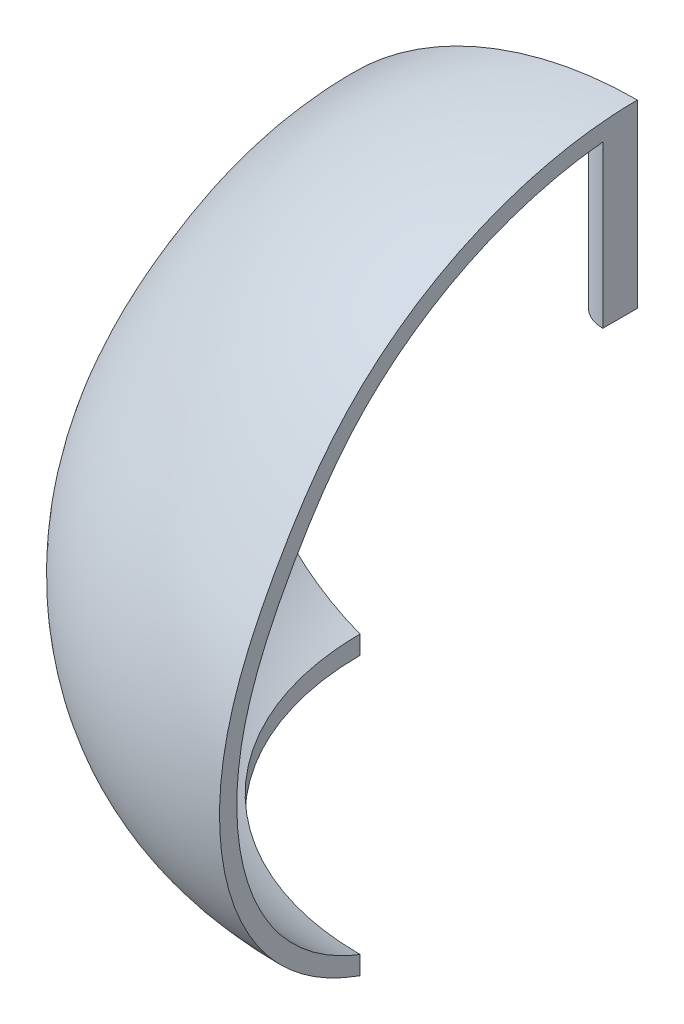
from build123d import *

# Parameters (mm, degrees)
SKETCH4_R           = 80.100145108
CUT_EXTRUDE2_DEPTH  = 20
CUT_EXTRUDE3_DEPTH  = 121.706010599
BOSS_EXTRUDE1_REACH = 54.085
SKETCH6_R           = 10
SKETCH7_W           = 348.912782296
SKETCH7_H           = 364.592796888
CUT_EXTRUDE4_DEPTH  = 159
SKETCH8_W           = 326.819124442
SKETCH8_H           = 332.894396065
CUT_EXTRUDE5_DEPTH  = 200


with BuildPart() as part:
    # Sketch3 → Revolve5 (revolve)
    with BuildSketch(Plane.XY):
        with BuildLine():
            Line((0.02453969, 157.084900749), (0.02453969, 152.084900749))
            add(Edge.make_bspline(
                [(-103.174583613, -2.6432e-05), (-114.760245555, 14.576189089), (-119.836740195, 49.27275863), (-101.45175109, 88.673946708), (-71.379831841, 134.479430747), (-29.75001244, 152.084900749), (0.02453969, 152.084900749)],
                knots=[0, 0, 0, 0, 0.250738493, 0.442513363, 0.587644713, 1, 1, 1, 1], degree=3))
            add(Edge.make_bspline(
                [(-103.174583613, -2.6432e-05), (-78.832759046, -30.064140021), (-33.458723298, -20.943389124), (0.02453969, -20.943389124)],
                knots=[0, 0, 0, 0, 1, 1, 1, 1], degree=3))
            Line((0.02453969, -20.943389124), (0.02453969, -25.943389124))
            add(Edge.make_bspline(
                [(0.02453969, -25.943389124), (-1.007843071, -25.943389124), (-3.05274325, -25.960735741), (-7.300680211, -26.054029266), (-12.774839269, -26.259816275), (-19.586870399, -26.581007249), (-28.911339242, -27.014332449), (-40.900445748, -27.386982651), (-55.443773123, -26.975342887), (-69.789912797, -25.08625158), (-81.278725906, -21.722461367), (-89.959801918, -17.60281584), (-96.13825684, -13.717797758), (-100.945853349, -9.752185194), (-104.534382709, -6.13029221), (-106.254478554, -4.141899361), (-107.07473695, -3.128814187)],
                knots=[-0.000194385, -0.000194385, -0.000194385, -0.000194385, 0.03106169, 0.062317764, 0.124829913, 0.187342062, 0.249854211, 0.37487851, 0.499902808, 0.624927106, 0.749951404, 0.812463553, 0.874975702, 0.937487851, 0.968743925, 1, 1, 1, 1], degree=3))
            add(Edge.make_bspline(
                [(-107.07473695, -3.128814187), (-107.861659129, -2.138767408), (-109.375579618, -0.100482773), (-112.095489807, 4.115600278), (-114.955951775, 9.644100323), (-117.55365357, 16.585319153), (-119.962688147, 26.134623726), (-121.103112226, 38.406473215), (-119.79356064, 53.088411426), (-116.089945574, 67.047457773), (-110.633897624, 80.23296506), (-104.034329909, 92.718986198), (-96.815301706, 104.751602155), (-88.512248671, 116.246845317), (-78.667704424, 126.697829164), (-67.464684594, 135.71357688), (-55.182594106, 143.280590712), (-42.054195525, 149.310974483), (-28.321126938, 153.731407172), (-14.204212291, 156.457352496), (-4.722534611, 157.084900749), (0.02453969, 157.084900749)],
                knots=[-0.000101258, -0.000101258, -0.000101258, -0.000101258, 0.015525324, 0.031151906, 0.06240507, 0.093658235, 0.124911399, 0.187417728, 0.249924056, 0.312430385, 0.374936714, 0.437443042, 0.499949371, 0.562455699, 0.624962028, 0.687468357, 0.749974685, 0.812481014, 0.874987343, 0.937493671, 1, 1, 1, 1], degree=3))
        make_face()
    revolve(axis=Axis((0.02453969, 171.610282588, 0), (0, -1, 0)))

    # Sketch4 → Cut-Extrude2 (cut)
    with BuildSketch(Plane(origin=(0, -30, 0), x_dir=(1, 0, 0), z_dir=(0, 1, 0))):
        Circle(SKETCH4_R)
    extrude(amount=CUT_EXTRUDE2_DEPTH, mode=Mode.SUBTRACT)

    # Sketch5 → Cut-Extrude3 (cut, through all)
    with BuildSketch(Plane(origin=(0, 0, 0), x_dir=(0, 0, -1), z_dir=(1, 0, 0))):
        with BuildLine():
            Line((-52.476481645, 8.136577936), (52.476481645, 8.136577936))
            ThreePointArc((52.476481645, 8.136577936), (58.138069368, 8.954648303), (63.336499377, 11.341935492))
            add(Edge.make_bspline(
                [(63.336499377, 11.341935492), (82.622361185, 23.812864951), (78.746201445, 39.317958114)],
                knots=[5.637022825, 5.637022825, 5.637022825, 6.404500867, 6.404500867, 6.404500867], degree=2, weights=[1, 0.927271268, 1]))
            ThreePointArc((78.746201445, 39.317958114), (77.929706658, 42.769255575), (77.20089719, 46.240127895))
            add(Edge.make_bspline(
                [(70.494135614, 63.047069033), (72.356334923, 60.10156835), (75.045149162, 54.673263207), (76.692738831, 48.822390655), (77.20089719, 46.240127895)],
                knots=[0.168181527, 0.168181527, 0.168181527, 0.168181527, 0.552818848, 0.845617793, 0.845617793, 0.845617793, 0.845617793], degree=3))
            ThreePointArc((70.494135614, 63.047069033), (68.293855497, 66.646255249), (66.203011989, 70.31009851))
            add(Edge.make_bspline(
                [(66.203011989, 70.31009851), (-4.427969211, 198.528374497), (-67.022107814, 68.723719713)],
                knots=[0.328274459, 0.328274459, 0.328274459, 2.851830568, 2.851830568, 2.851830568], degree=2, weights=[1, 0.304123557, 1]))
            ThreePointArc((-67.022107814, 68.723719713), (-68.159373057, 66.423614108), (-69.341813393, 64.146402461))
            add(Edge.make_bspline(
                [(-69.341813393, 64.146402461), (-73.061653072, 57.152172395), (-75.898874077, 49.79082496), (-77.836559233, 42.105665134)],
                knots=[0.114274397, 0.114274397, 0.114274397, 0.114274397, 1, 1, 1, 1], degree=3))
            add(Edge.make_bspline(
                [(-77.836559233, 42.105665134), (-84.680776254, 25.143909909), (-63.336499377, 11.341935492)],
                knots=[2.947295522, 2.947295522, 2.947295522, 3.787755136, 3.787755136, 3.787755136], degree=2, weights=[1, 0.91299521, 1]))
            ThreePointArc((-63.336499377, 11.341935492), (-58.138069368, 8.954648303), (-52.476481645, 8.136577936))
        make_face()
    extrude(amount=CUT_EXTRUDE3_DEPTH, mode=Mode.SUBTRACT)

    # Sketch6 → Boss-Extrude1 (add, up to next)
    with BuildSketch(Plane(origin=(0, 105, 0), x_dir=(1, 0, 0), z_dir=(0, 1, 0)), mode=Mode.PRIVATE) as boss_extrude1_sk1:
        Circle(SKETCH6_R)
    boss_extrude1_tool1 = extrude(boss_extrude1_sk1.sketch, amount=BOSS_EXTRUDE1_REACH, mode=Mode.PRIVATE) - part.part
    add(boss_extrude1_tool1.solids().sort_by_distance((0, 105, 0))[0])

    # Sketch7 → Cut-Extrude4 (cut)
    with BuildSketch(Plane.XY):
        Rectangle(SKETCH7_W, SKETCH7_H)
    extrude(amount=-CUT_EXTRUDE4_DEPTH, mode=Mode.SUBTRACT)

    # Sketch8 → Cut-Extrude5 (cut)
    with BuildSketch(Plane(origin=(0, 0, 0), x_dir=(0, 0, -1), z_dir=(1, 0, 0))):
        with Locations((0, -2.6432e-05)):
            Rectangle(SKETCH8_W, SKETCH8_H)
    extrude(amount=CUT_EXTRUDE5_DEPTH, mode=Mode.SUBTRACT)


solid = part.part
